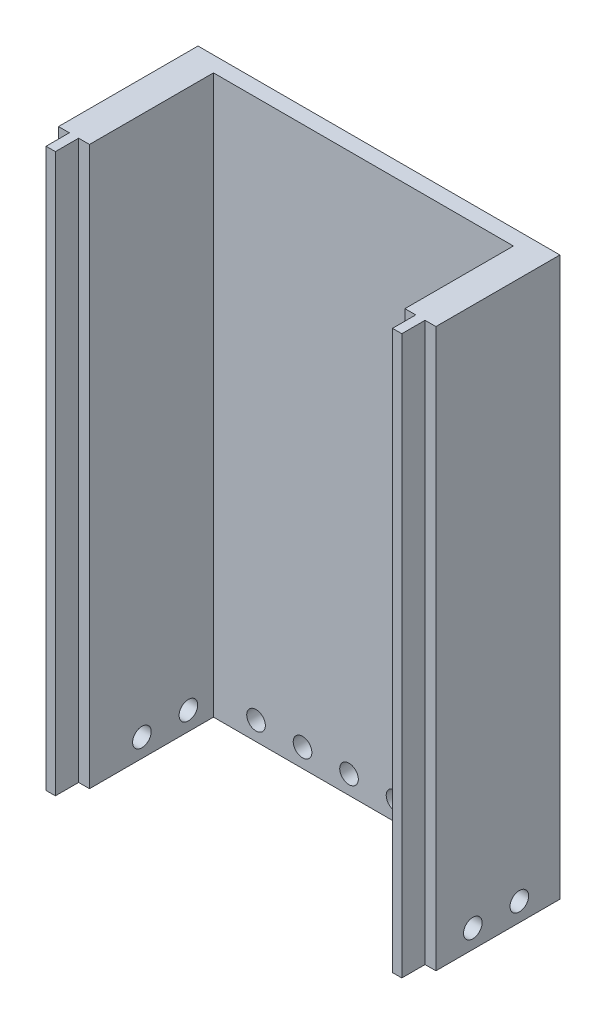
from build123d import *

# Parameters (mm, degrees)
BOSS_EXTRUDE1_DEPTH = 18
SKETCH5_R           = 0.3
CUT_EXTRUDE1_DEPTH  = 1.5
SKETCH6_R           = 0.3
CUT_EXTRUDE2_DEPTH  = 12.675000001


with BuildPart() as part:
    # Sketch1 → Boss-Extrude1 (new body)
    with BuildSketch(Plane(origin=(0, 0, 0), x_dir=(1, 0, 0), z_dir=(0, 1, 0))):
        Polygon((-8.372296156, -12.19086985), (-8.372296156, -16.69086985), (-8.022296156, -16.69086985), (-8.022296156, -17.44086985), (-7.722296156, -17.44086985), (-7.722296156, -16.69086985), (-7.372296156, -16.69086985), (-7.372296156, -12.69086985), (2.302703845, -12.69086985), (2.302703845, -16.19086985), (2.652703845, -16.19086985), (2.652703845, -16.94086985), (2.952703845, -16.94086985), (2.952703845, -16.19086985), (3.302703845, -16.19086985), (3.302703845, -12.19086985), align=None)
    extrude(amount=BOSS_EXTRUDE1_DEPTH)

    # Sketch5 → Cut-Extrude1 (cut, through all)
    with BuildSketch(Plane.XY.offset(12.69086985)):
        with Locations((-6, 0.6)):
            Circle(SKETCH5_R)
        with Locations((-4.5, 0.6)):
            Circle(SKETCH5_R)
        with Locations((-3, 0.6)):
            Circle(SKETCH5_R)
        with Locations((-1.5, 0.6)):
            Circle(SKETCH5_R)
        with Locations((1.5, 0.6)):
            Circle(SKETCH5_R)
        with Locations((0, 0.6)):
            Circle(SKETCH5_R)
    extrude(amount=-CUT_EXTRUDE1_DEPTH, mode=Mode.SUBTRACT)

    # Sketch6 → Cut-Extrude2 (cut, through all)
    with BuildSketch(Plane(origin=(3.302703845, 0, 0), x_dir=(0, 0, -1), z_dir=(1, 0, 0))):
        with Locations((-15, 0.6)):
            Circle(SKETCH6_R)
        with Locations((-13.5, 0.6)):
            Circle(SKETCH6_R)
    extrude(amount=-CUT_EXTRUDE2_DEPTH, mode=Mode.SUBTRACT)


solid = part.part
